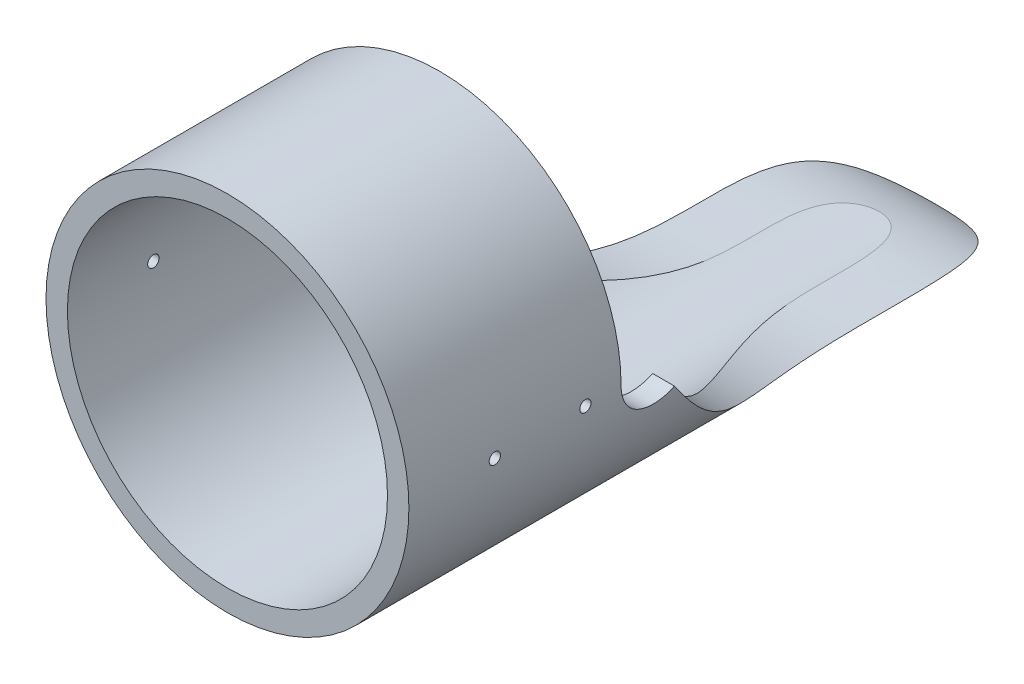
from build123d import *

# Parameters (mm, degrees)
SKETCH1_R               = 50.875
SKETCH1_R_2             = 44.875
BOSS_EXTRUDE1_DEPTH     = 258
SKETCH2_OUTSIDE_W       = 319.084
SKETCH2_OUTSIDE_H       = 162.834
CUT_EXTRUDE1_DEPTH      = 51.875
CUT_EXTRUDE1_DEPTH_BACK = 51.875
SKETCH4_R               = 1.5875
CUT_EXTRUDE3_DEPTH      = 51.8750001
CUT_EXTRUDE3_DEPTH_BACK = 51.8750001


with BuildPart() as part:
    # Sketch1 → Boss-Extrude1 (new body)
    with BuildSketch(Plane.XY):
        Circle(SKETCH1_R)
        Circle(SKETCH1_R_2, mode=Mode.SUBTRACT)
    extrude(amount=BOSS_EXTRUDE1_DEPTH)

    # Sketch2 outside → Cut-Extrude1 (cut, two sides)
    with BuildSketch(Plane(origin=(0, 0, 0), x_dir=(0, 0, -1), z_dir=(1, 0, 0))) as cut_extrude1_sk:
        with Locations((-129, 0)):
            Rectangle(SKETCH2_OUTSIDE_W, SKETCH2_OUTSIDE_H)
        with BuildLine():
            Line((-198.5, -50.875), (0, -50.875))
            add(Edge.make_bspline(
                [(-123.386550588, -8.275819337), (-81.752620628, -64.643145872), (-28.413904024, -31.213109934), (0, -50.875)],
                knots=[0.043569277, 0.043569277, 0.043569277, 0.043569277, 1, 1, 1, 1], degree=3))
            ThreePointArc((-123.386550588, -8.275819337), (-133.683241713, -8.835567161), (-139, 0))
            Line((-139, 0), (-139, 50.875))
            Line((-139, 50.875), (-198.5, 50.875))
            Line((-198.5, 50.875), (-198.5, -50.875))
        make_face(mode=Mode.SUBTRACT)
    extrude(amount=CUT_EXTRUDE1_DEPTH, mode=Mode.SUBTRACT)
    extrude(cut_extrude1_sk.sketch, amount=-CUT_EXTRUDE1_DEPTH_BACK, mode=Mode.SUBTRACT)

    # Sketch4 → Cut-Extrude3 (cut, two sides)
    with BuildSketch(Plane(origin=(0, 0, 0), x_dir=(0, 0, -1), z_dir=(1, 0, 0))) as cut_extrude3_sk:
        with Locations((-149, 0)):
            Circle(SKETCH4_R)
        with Locations((-174.4, 0)):
            Circle(SKETCH4_R)
    extrude(amount=CUT_EXTRUDE3_DEPTH, mode=Mode.SUBTRACT)
    extrude(cut_extrude3_sk.sketch, amount=-CUT_EXTRUDE3_DEPTH_BACK, mode=Mode.SUBTRACT)


solid = part.part
